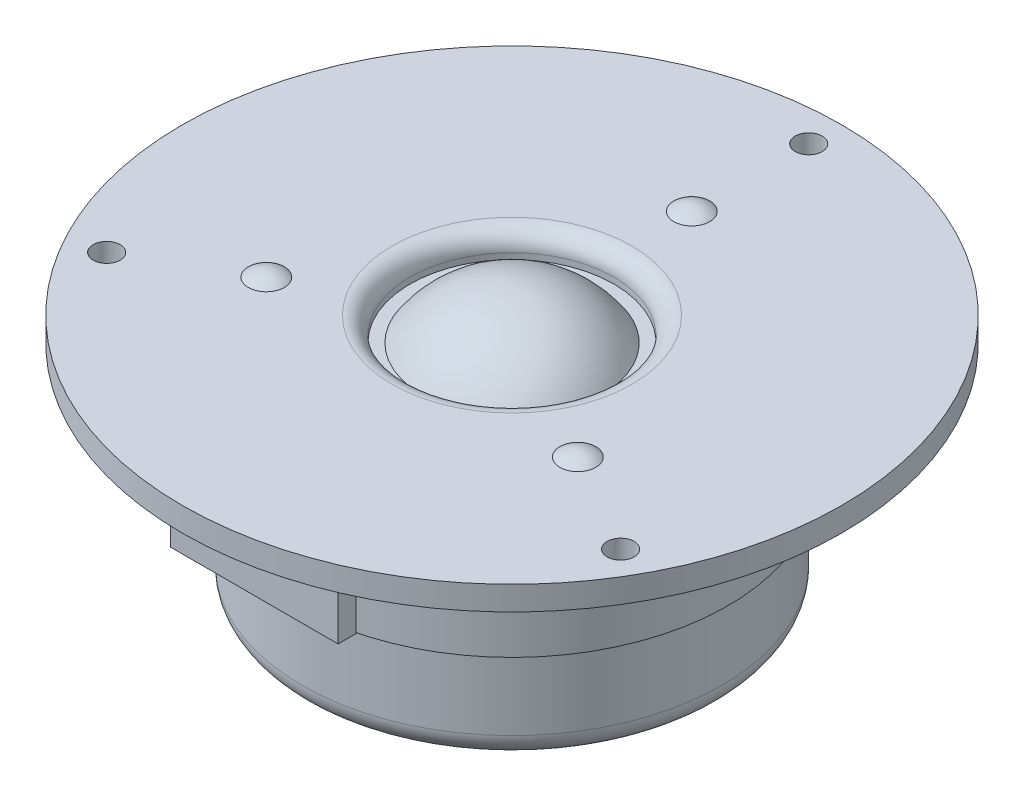
from build123d import *

# Parameters (mm, degrees)
FILLET1_R                = 4
FILLET2_R                = 3
M4_CLEARANCE_HOLE1_D     = 4.5
M4_CLEARANCE_HOLE1_DEPTH = 12
CIRPATTERN1_COUNT        = 3
SKETCH7_W                = 28
SKETCH7_H                = 3
BOSS_EXTRUDE1_DEPTH      = 15


with BuildPart() as part:
    # Sketch2 → Revolve1 (revolve)
    with BuildSketch(Plane.XY):
        with BuildLine():
            Line((0, 8.050125629), (0, -36))
            Line((0, -36), (35, -36))
            Line((35, -36), (35, -20))
            Line((35, -20), (36, -20))
            Line((36, -20), (36, -8))
            Line((36, -8), (35, -8))
            Line((35, -8), (35, -4))
            Line((35, -4), (37, -4))
            Line((37, -4), (37, 0))
            Line((37, 0), (55, 0))
            Line((55, 0), (55, 4))
            Line((55, 4), (17, 4))
            Line((17, 4), (17, 0))
            Line((17, 0), (15, 0))
            ThreePointArc((15, 0), (8.511822993, 5.91041785), (0, 8.050125629))
        make_face()
    revolve(axis=Axis((0, 0, 0), (0, 1, 0)))

    # Fillet1
    fillet1_edges = [part.edges().sort_by_distance(p)[0] for p in [
        (-35, -36, 0),
    ]]
    fillet(fillet1_edges, radius=FILLET1_R)

    # Fillet2
    fillet2_edges = [part.edges().sort_by_distance(p)[0] for p in [
        (-17, 4, 0),
    ]]
    fillet(fillet2_edges, radius=FILLET2_R)

    # M4 Clearance Hole1
    with Locations(Plane(origin=(0, 4, 0), x_dir=(1, 0, 0), z_dir=(0, 1, 0))):
        with Locations((0, 49.5)):
            m4_clearance_hole1 = Hole(M4_CLEARANCE_HOLE1_D / 2, depth=M4_CLEARANCE_HOLE1_DEPTH)

    # Sketch6 → Revolve3 (revolve)
    with BuildSketch(Plane(origin=(0, 0, 0), x_dir=(0, 0, -1), z_dir=(1, 0, 0))):
        with BuildLine():
            Line((33, 4), (30, 4))
            Line((30, 4), (30, 5))
            ThreePointArc((30, 5), (31.58113883, 4.74341649), (33, 4))
        make_face()
    revolve3 = revolve(axis=Axis((0, 5, -30), (0, -1, 0)))

    # CirPattern1: M4 Clearance Hole1, Revolve3 ×3 about axis
    cirpattern1_axis = Axis((0, 0, 0), (0, 1, 0))
    for i in range(1, CIRPATTERN1_COUNT):
        add(m4_clearance_hole1.rotate(cirpattern1_axis, i * 360 / CIRPATTERN1_COUNT), mode=Mode.SUBTRACT)
        add(revolve3.rotate(cirpattern1_axis, i * 360 / CIRPATTERN1_COUNT))

    # Sketch7 → Boss-Extrude1 (add)
    with BuildSketch(Plane.XZ):
        with Locations((0, 41.5)):
            Rectangle(SKETCH7_W, SKETCH7_H)
    extrude(amount=BOSS_EXTRUDE1_DEPTH)


solid = part.part
